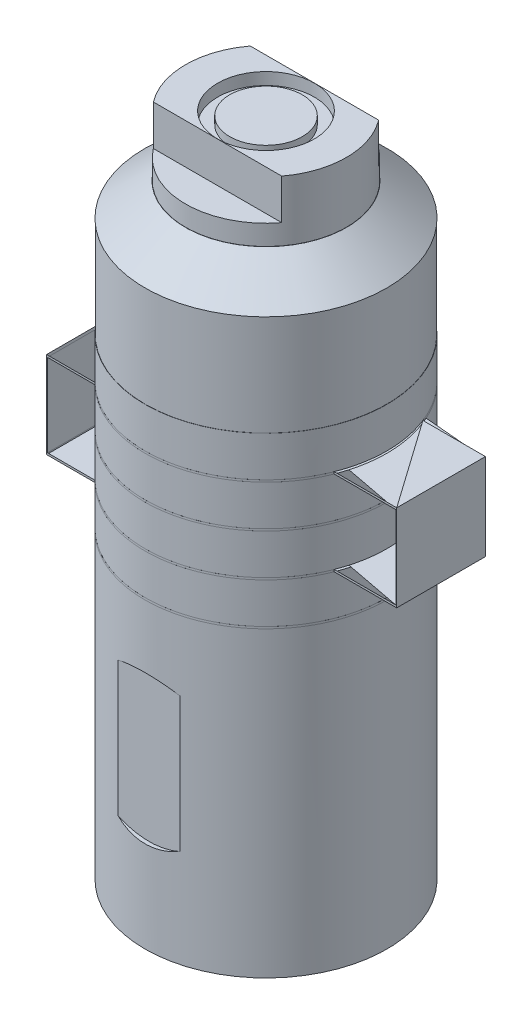
from build123d import *

# Parameters (mm, degrees)
SKETCH1_R                  = 30
BOSS_EXTRUDE1_DEPTH        = 10
SKETCH2_R                  = 15
CUT_EXTRUDE1_DEPTH         = 10
CUT_EXTRUDE4_DEPTH         = 0.01
BOSS_EXTRUDE2_DEPTH        = 0.5
SKETCH9_R                  = 30
BOSS_EXTRUDE3_DEPTH        = 10
BOSS_EXTRUDE4_DEPTH        = 0.5
LPATTERN1_COUNT            = 2
LPATTERN1_PITCH            = 21
SKETCH11_R                 = 30
BOSS_EXTRUDE5_DEPTH        = 10
LPATTERN2_COUNT            = 2
LPATTERN2_PITCH            = 21
SKETCH12_R                 = 30
BOSS_EXTRUDE6_DEPTH        = 10
SKETCH13_W                 = 0.2
SKETCH13_H                 = 22
BOSS_EXTRUDE7_DEPTH        = 20.5
SKETCH14_W                 = 0.2
SKETCH14_H                 = 22
BOSS_EXTRUDE8_DEPTH        = 20.5
SKETCH15_R                 = 30
BOSS_EXTRUDE9_DEPTH        = 75
SKETCH16_R                 = 18
CUT_EXTRUDE5_DEPTH         = 2
SKETCH42_R                 = 29.95
BOSS_EXTRUDE10_DEPTH       = 25
SKETCH46_R                 = 19.95
BOSS_EXTRUDE11_DEPTH       = 15
CUT_EXTRUDE8_DEPTH         = 10
SKETCH48_R                 = 12
CUT_EXTRUDE9_DEPTH         = 3
SKETCH49_R                 = 9
BOSS_EXTRUDE12_DEPTH       = 2
CUT_EXTRUDE10_DEPTH        = 1
M20X1_5_TAPPED_HOLE1_D     = 18.5
M20X1_5_TAPPED_HOLE1_DEPTH = 34.5
M20X1_5_TAPPED_HOLE1_TIP   = 5.557960726


with BuildPart() as part:
    # Sketch1 → Boss-Extrude1 (new body)
    with BuildSketch(Plane(origin=(0, 0, 0), x_dir=(1, 0, 0), z_dir=(0, 1, 0))):
        with Locations(Location((0, 0, 0), (0, 0, 270))):  # turned: the seam where the file's is
            Circle(SKETCH1_R)
    extrude(amount=BOSS_EXTRUDE1_DEPTH)

    # Sketch2 → Cut-Extrude1 (cut)
    with BuildSketch(Plane.XZ):
        with Locations(Location((0, 0, 0), (0, 0, 270))):  # turned: the seam where the file's is
            Circle(SKETCH2_R)
    extrude(amount=-CUT_EXTRUDE1_DEPTH, mode=Mode.SUBTRACT)

    # Sketch7 → Cut-Extrude4 (cut)
    with BuildSketch(Plane(origin=(0, 10, 0), x_dir=(1, 0, 0), z_dir=(0, 1, 0))):
        Polygon((0, -23.5), (-0.5, -23.5), (-0.5, -22), (-2, -22), (-2, -21.5), (-0.5, -21.5), (-0.5, -20), (0, -20), (0, -21.5), (1.5, -21.5), (1.5, -22), (0, -22), align=None)
    extrude(amount=-CUT_EXTRUDE4_DEPTH, mode=Mode.SUBTRACT)

    # Sketch8 → Boss-Extrude2 (add)
    with BuildSketch(Plane(origin=(0, 10, 0), x_dir=(1, 0, 0), z_dir=(0, 1, 0))):
        with BuildLine():
            Line((27.915945712, 11), (43.415945712, 11))
            Line((43.415945712, 11), (43.415945712, -11))
            Line((43.415945712, -11), (27.915945712, -11))
            ThreePointArc((27.915945712, -11), (-30.005, 0), (27.915945712, 11))
        make_face()
    boss_extrude2 = extrude(amount=BOSS_EXTRUDE2_DEPTH)

    # Sketch9 → Boss-Extrude3 (add)
    with BuildSketch(Plane(origin=(0, 10.5, 0), x_dir=(1, 0, 0), z_dir=(0, 1, 0))):
        with Locations(Location((0, 0, 0), (0, 0, 270))):  # turned: the seam where the file's is
            Circle(SKETCH9_R)
    extrude(amount=BOSS_EXTRUDE3_DEPTH)

    # Sketch10 → Boss-Extrude4 (add)
    with BuildSketch(Plane(origin=(0, 20.5, 0), x_dir=(1, 0, 0), z_dir=(0, 1, 0))):
        with BuildLine():
            Line((-43.415945712, 11), (-27.915945712, 11))
            ThreePointArc((-27.915945712, 11), (30.005, 0), (-27.915945712, -11))
            Line((-27.915945712, -11), (-43.415945712, -11))
            Line((-43.415945712, -11), (-43.415945712, 11))
        make_face()
    boss_extrude4 = extrude(amount=BOSS_EXTRUDE4_DEPTH)

    # LPattern1: Boss-Extrude4 ×2
    with Locations(*[(0, -i * LPATTERN1_PITCH, 0) for i in range(1, LPATTERN1_COUNT)]):
        add(boss_extrude4)

    # Sketch11 → Boss-Extrude5 (add)
    with BuildSketch(Plane(origin=(0, 21, 0), x_dir=(1, 0, 0), z_dir=(0, 1, 0))):
        with Locations(Location((0, 0, 0), (0, 0, 270))):  # turned: the seam where the file's is
            Circle(SKETCH11_R)
    extrude(amount=BOSS_EXTRUDE5_DEPTH)

    # LPattern2: Boss-Extrude2 ×2
    with Locations(*[(0, i * LPATTERN2_PITCH, 0) for i in range(1, LPATTERN2_COUNT)]):
        add(boss_extrude2)

    # Sketch12 → Boss-Extrude6 (add)
    with BuildSketch(Plane(origin=(0, 31.5, 0), x_dir=(1, 0, 0), z_dir=(0, 1, 0))):
        with Locations(Location((0, 0, 0), (0, 0, 270))):  # turned: the seam where the file's is
            Circle(SKETCH12_R)
    extrude(amount=BOSS_EXTRUDE6_DEPTH)

    # Sketch13 → Boss-Extrude7 (add)
    with BuildSketch(Plane.XZ.offset(-31)):
        with Locations((43.315945712, 0)):
            Rectangle(SKETCH13_W, SKETCH13_H)
    extrude(amount=BOSS_EXTRUDE7_DEPTH)

    # Sketch14 → Boss-Extrude8 (add)
    with BuildSketch(Plane.XZ.offset(-20.5)):
        with Locations((-43.315945712, 0)):
            Rectangle(SKETCH14_W, SKETCH14_H)
    extrude(amount=BOSS_EXTRUDE8_DEPTH)

    # Sketch15 → Boss-Extrude9 (add)
    with BuildSketch(Plane.XZ.offset(0.5)):
        with Locations(Location((0, 0, 0), (0, 0, 90))):  # turned: the seam where the file's is
            Circle(SKETCH15_R)
    extrude(amount=BOSS_EXTRUDE9_DEPTH)

    # Sketch16 → Cut-Extrude5 (cut)
    with BuildSketch(Plane.XZ.offset(75.5)):
        with Locations(Location((0, 0, 0), (0, 0, 270))):  # turned: the seam where the file's is
            Circle(SKETCH16_R)
    extrude(amount=-CUT_EXTRUDE5_DEPTH, mode=Mode.SUBTRACT)

    # Sketch42 → Boss-Extrude10 (add)
    with BuildSketch(Plane(origin=(0, 41.5, 0), x_dir=(1, 0, 0), z_dir=(0, 1, 0))):
        with Locations(Location((0, 0, 0), (0, 0, 270))):  # turned: the seam where the file's is
            Circle(SKETCH42_R)
    extrude(amount=BOSS_EXTRUDE10_DEPTH)

    # Sketch45 → Revolve1 (revolve)
    with BuildSketch(Plane.XY, mode=Mode.PRIVATE) as revolve1_sk:
        Polygon((0, 66.5), (30, 66.5), (20, 74.5), (0, 74.5), align=None)
    revolve(revolve1_sk.sketch.rotate(Axis((0, 74.5, 0), (0, -1, 0)), 90), axis=Axis((0, 74.5, 0), (0, -1, 0)))  # turned: the seam where the file's is

    # Sketch46 → Boss-Extrude11 (add)
    with BuildSketch(Plane(origin=(0, 74.5, 0), x_dir=(1, 0, 0), z_dir=(0, 1, 0))):
        with Locations(Location((0, 0, 0), (0, 0, 180))):  # turned: the seam where the file's is
            Circle(SKETCH46_R)
    extrude(amount=BOSS_EXTRUDE11_DEPTH)

    # Sketch47 → Cut-Extrude8 (cut)
    with BuildSketch(Plane(origin=(0, 89.5, 0), x_dir=(1, 0, 0), z_dir=(0, 1, 0))):
        with BuildLine():
            Line((-15.922781257, 12.019464923), (15.922781257, 12.019464923))
            ThreePointArc((15.922781257, 12.019464923), (0, 19.95), (-15.922781257, 12.019464923))
        make_face()
        with BuildLine():
            Line((-15.922781257, -12.019464923), (15.922781257, -12.019464923))
            ThreePointArc((15.922781257, -12.019464923), (0, -19.95), (-15.922781257, -12.019464923))
        make_face()
    extrude(amount=-CUT_EXTRUDE8_DEPTH, mode=Mode.SUBTRACT)

    # Sketch48 → Cut-Extrude9 (cut)
    with BuildSketch(Plane(origin=(0, 89.5, 0), x_dir=(1, 0, 0), z_dir=(0, 1, 0))):
        with Locations(Location((0, 0, 0), (0, 0, 180))):  # turned: the seam where the file's is
            Circle(SKETCH48_R)
    extrude(amount=-CUT_EXTRUDE9_DEPTH, mode=Mode.SUBTRACT)

    # Sketch49 → Boss-Extrude12 (add)
    with BuildSketch(Plane(origin=(0, 86.5, 0), x_dir=(1, 0, 0), z_dir=(0, 1, 0))):
        with Locations(Location((0, 0, 0), (0, 0, 180))):  # turned: the seam where the file's is
            Circle(SKETCH49_R)
    extrude(amount=BOSS_EXTRUDE12_DEPTH)

    # Sketch50 → Cut-Extrude10 (cut)
    with BuildSketch(Plane.XY.offset(30)):
        with BuildLine():
            Line((-9.074878192, -50.5), (-9.074878192, -18.5))
            ThreePointArc((-9.074878192, -18.5), (0, -16.105614601), (9.074878192, -18.5))
            Line((9.074878192, -18.5), (9.074878192, -50.5))
            ThreePointArc((9.074878192, -50.5), (0, -52.894385399), (-9.074878192, -50.5))
        make_face()
    cut_extrude10 = extrude(amount=-CUT_EXTRUDE10_DEPTH, mode=Mode.SUBTRACT)

    # Mirror1: Cut-Extrude10 across plane
    add(cut_extrude10.mirror(Plane.XY), mode=Mode.SUBTRACT)

    # M20x1.5 Tapped Hole1
    with Locations(Plane(origin=(0, -73.5, 0), x_dir=(0, 0, -1), z_dir=(0, -1, 0))):
        with Locations((0, 0)):
            Hole(M20X1_5_TAPPED_HOLE1_D / 2, depth=M20X1_5_TAPPED_HOLE1_DEPTH)
            with Locations((0, 0, -(M20X1_5_TAPPED_HOLE1_DEPTH + M20X1_5_TAPPED_HOLE1_TIP / 2))):  # 118° drill point
                Cone(0, M20X1_5_TAPPED_HOLE1_D / 2, M20X1_5_TAPPED_HOLE1_TIP, mode=Mode.SUBTRACT)


solid = part.part
